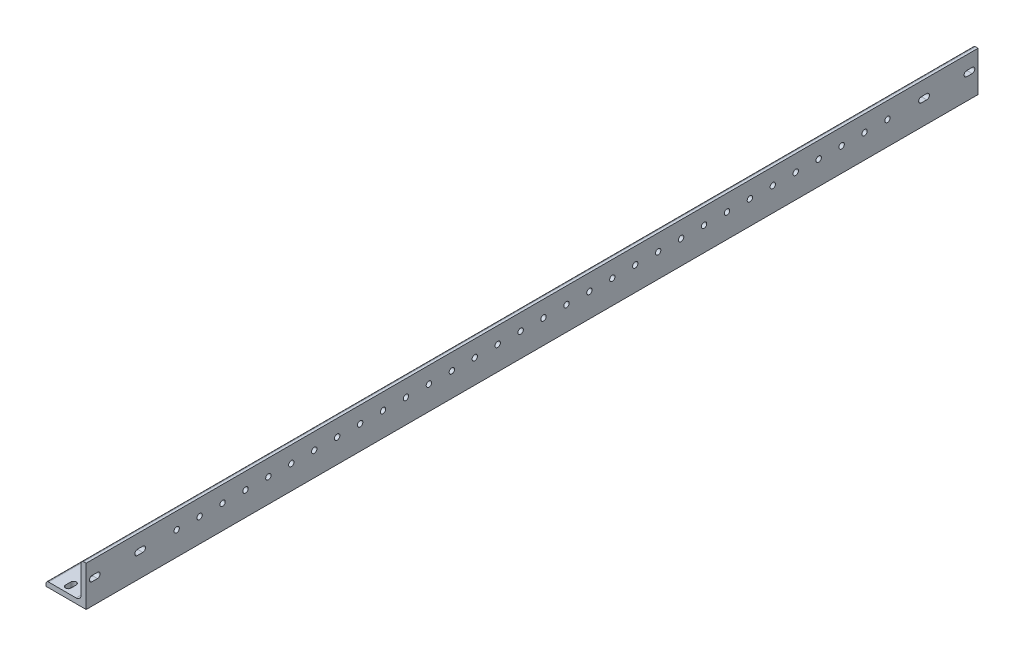
from build123d import *

# Parameters (mm, degrees)
BOSS_EXTRUDE1_DEPTH = 609.6
SKETCH3_W           = 655.2
SKETCH3_H           = 25.4
CUT_EXTRUDE2_DEPTH  = 30.48
SKETCH4_R           = 1.7
CUT_EXTRUDE4_DEPTH  = 611.137198198
SKETCH7_R           = 1.7
CUT_EXTRUDE6_DEPTH  = 611.137198198
CUT_EXTRUDE7_DEPTH  = 611.137198198
CUT_EXTRUDE8_DEPTH  = 611.137198198


with BuildPart() as part:
    # Sketch2 → Boss-Extrude1 (new, symmetric)
    with BuildSketch(Plane.XY):
        with BuildLine():
            Line((-12.7, -12.7), (12.7, -12.7))
            Line((12.7, -12.7), (12.7, 12.7))
            Line((12.7, 12.7), (11.1125, 12.7))
            ThreePointArc((11.1125, 12.7), (9.989967985, 12.235032015), (9.525, 11.1125))
            Line((9.525, 11.1125), (9.525, -6.35))
            ThreePointArc((9.525, -6.35), (8.59506403, -8.59506403), (6.35, -9.525))
            Line((6.35, -9.525), (-11.1125, -9.525))
            ThreePointArc((-11.1125, -9.525), (-12.235032015, -9.989967985), (-12.7, -11.1125))
            Line((-12.7, -11.1125), (-12.7, -12.7))
        make_face()
    extrude(amount=BOSS_EXTRUDE1_DEPTH, both=True)

    # Sketch3 → Cut-Extrude2 (cut)
    with BuildSketch(Plane(origin=(12.7, 0, 0), x_dir=(0, 0, -1), z_dir=(1, 0, 0))):
        with Locations((282, 0)):
            Rectangle(SKETCH3_W, SKETCH3_H)
    extrude(amount=-CUT_EXTRUDE2_DEPTH, mode=Mode.SUBTRACT)

    # Sketch4 → Cut-Extrude4 (cut, through all)
    with BuildSketch(Plane(origin=(0, -9.525, 0), x_dir=(1, 0, 0), z_dir=(0, 1, 0))):
        with Locations(Location((-2.38125, -552.35, 0), (0, 0, 180))):
            Circle(SKETCH4_R)
        with Locations(Location((-2.38125, -537.85, 0), (0, 0, 180))):
            Circle(SKETCH4_R)
        with Locations(Location((-2.38125, -523.35, 0), (0, 0, 180))):
            Circle(SKETCH4_R)
        with Locations(Location((-2.38125, -508.85, 0), (0, 0, 180))):
            Circle(SKETCH4_R)
        with Locations(Location((-2.38125, -494.35, 0), (0, 0, 180))):
            Circle(SKETCH4_R)
        with Locations(Location((-2.38125, -479.85, 0), (0, 0, 180))):
            Circle(SKETCH4_R)
        with Locations(Location((-2.38125, -465.35, 0), (0, 0, 180))):
            Circle(SKETCH4_R)
        with Locations(Location((-2.38125, -450.85, 0), (0, 0, 180))):
            Circle(SKETCH4_R)
        with Locations(Location((-2.38125, -436.35, 0), (0, 0, 180))):
            Circle(SKETCH4_R)
        with Locations(Location((-2.38125, -421.85, 0), (0, 0, 180))):
            Circle(SKETCH4_R)
        with Locations(Location((-2.38125, -407.35, 0), (0, 0, 180))):
            Circle(SKETCH4_R)
        with Locations(Location((-2.38125, -392.85, 0), (0, 0, 180))):
            Circle(SKETCH4_R)
        with Locations(Location((-2.38125, -378.35, 0), (0, 0, 180))):
            Circle(SKETCH4_R)
        with Locations(Location((-2.38125, -363.85, 0), (0, 0, 180))):
            Circle(SKETCH4_R)
        with Locations(Location((-2.38125, -349.35, 0), (0, 0, 180))):
            Circle(SKETCH4_R)
        with Locations(Location((-2.38125, -334.85, 0), (0, 0, 180))):
            Circle(SKETCH4_R)
        with Locations(Location((-2.38125, -320.35, 0), (0, 0, 180))):
            Circle(SKETCH4_R)
        with Locations(Location((-2.38125, -305.85, 0), (0, 0, 180))):
            Circle(SKETCH4_R)
        with Locations(Location((-2.38125, -291.35, 0), (0, 0, 180))):
            Circle(SKETCH4_R)
        with Locations(Location((-2.38125, -276.85, 0), (0, 0, 180))):
            Circle(SKETCH4_R)
        with Locations(Location((-2.38125, -262.35, 0), (0, 0, 180))):
            Circle(SKETCH4_R)
        with Locations(Location((-2.38125, -247.85, 0), (0, 0, 180))):
            Circle(SKETCH4_R)
        with Locations(Location((-2.38125, -233.35, 0), (0, 0, 180))):
            Circle(SKETCH4_R)
        with Locations(Location((-2.38125, -218.85, 0), (0, 0, 180))):
            Circle(SKETCH4_R)
        with Locations(Location((-2.38125, -204.35, 0), (0, 0, 180))):
            Circle(SKETCH4_R)
        with Locations(Location((-2.38125, -189.85, 0), (0, 0, 180))):
            Circle(SKETCH4_R)
        with Locations(Location((-2.38125, -175.35, 0), (0, 0, 180))):
            Circle(SKETCH4_R)
        with Locations(Location((-2.38125, -160.85, 0), (0, 0, 180))):
            Circle(SKETCH4_R)
        with Locations(Location((-2.38125, -146.35, 0), (0, 0, 180))):
            Circle(SKETCH4_R)
        with Locations(Location((-2.38125, -131.85, 0), (0, 0, 180))):
            Circle(SKETCH4_R)
        with Locations(Location((-2.38125, -117.35, 0), (0, 0, 180))):
            Circle(SKETCH4_R)
        with Locations(Location((-2.38125, -102.85, 0), (0, 0, 180))):
            Circle(SKETCH4_R)
    extrude(amount=-CUT_EXTRUDE4_DEPTH, mode=Mode.SUBTRACT)

    # Sketch7 → Cut-Extrude6 (cut, through all)
    with BuildSketch(Plane.ZY.offset(-9.525)):
        with Locations(Location((552.35, 2.38125, 0), (0, 0, 270))):
            Circle(SKETCH7_R)
        with Locations(Location((537.85, 2.38125, 0), (0, 0, 270))):
            Circle(SKETCH7_R)
        with Locations(Location((523.35, 2.38125, 0), (0, 0, 270))):
            Circle(SKETCH7_R)
        with Locations(Location((508.85, 2.38125, 0), (0, 0, 270))):
            Circle(SKETCH7_R)
        with Locations(Location((494.35, 2.38125, 0), (0, 0, 270))):
            Circle(SKETCH7_R)
        with Locations(Location((479.85, 2.38125, 0), (0, 0, 270))):
            Circle(SKETCH7_R)
        with Locations(Location((465.35, 2.38125, 0), (0, 0, 270))):
            Circle(SKETCH7_R)
        with Locations(Location((450.85, 2.38125, 0), (0, 0, 270))):
            Circle(SKETCH7_R)
        with Locations(Location((436.35, 2.38125, 0), (0, 0, 270))):
            Circle(SKETCH7_R)
        with Locations(Location((421.85, 2.38125, 0), (0, 0, 270))):
            Circle(SKETCH7_R)
        with Locations(Location((407.35, 2.38125, 0), (0, 0, 270))):
            Circle(SKETCH7_R)
        with Locations(Location((392.85, 2.38125, 0), (0, 0, 270))):
            Circle(SKETCH7_R)
        with Locations(Location((378.35, 2.38125, 0), (0, 0, 270))):
            Circle(SKETCH7_R)
        with Locations(Location((363.85, 2.38125, 0), (0, 0, 270))):
            Circle(SKETCH7_R)
        with Locations(Location((349.35, 2.38125, 0), (0, 0, 270))):
            Circle(SKETCH7_R)
        with Locations(Location((334.85, 2.38125, 0), (0, 0, 270))):
            Circle(SKETCH7_R)
        with Locations(Location((320.35, 2.38125, 0), (0, 0, 270))):
            Circle(SKETCH7_R)
        with Locations(Location((305.85, 2.38125, 0), (0, 0, 270))):
            Circle(SKETCH7_R)
        with Locations(Location((291.35, 2.38125, 0), (0, 0, 270))):
            Circle(SKETCH7_R)
        with Locations(Location((276.85, 2.38125, 0), (0, 0, 270))):
            Circle(SKETCH7_R)
        with Locations(Location((262.35, 2.38125, 0), (0, 0, 270))):
            Circle(SKETCH7_R)
        with Locations(Location((247.85, 2.38125, 0), (0, 0, 270))):
            Circle(SKETCH7_R)
        with Locations(Location((233.35, 2.38125, 0), (0, 0, 270))):
            Circle(SKETCH7_R)
        with Locations(Location((218.85, 2.38125, 0), (0, 0, 270))):
            Circle(SKETCH7_R)
        with Locations(Location((204.35, 2.38125, 0), (0, 0, 270))):
            Circle(SKETCH7_R)
        with Locations(Location((189.85, 2.38125, 0), (0, 0, 270))):
            Circle(SKETCH7_R)
        with Locations(Location((175.35, 2.38125, 0), (0, 0, 270))):
            Circle(SKETCH7_R)
        with Locations(Location((160.85, 2.38125, 0), (0, 0, 270))):
            Circle(SKETCH7_R)
        with Locations(Location((146.35, 2.38125, 0), (0, 0, 270))):
            Circle(SKETCH7_R)
        with Locations(Location((131.85, 2.38125, 0), (0, 0, 270))):
            Circle(SKETCH7_R)
        with Locations(Location((117.35, 2.38125, 0), (0, 0, 270))):
            Circle(SKETCH7_R)
        with Locations(Location((102.85, 2.38125, 0), (0, 0, 270))):
            Circle(SKETCH7_R)
    extrude(amount=-CUT_EXTRUDE6_DEPTH, mode=Mode.SUBTRACT)

    # Sketch8 → Cut-Extrude7 (cut, through all)
    with BuildSketch(Plane.ZY.offset(-9.525)):
        with BuildLine():
            Line((49.3305, 4.0825), (52.7305, 4.0825))
            ThreePointArc((52.7305, 4.0825), (54.4305, 2.3825), (52.7305, 0.6825))
            Line((52.7305, 0.6825), (49.3305, 0.6825))
            ThreePointArc((49.3305, 0.6825), (47.6305, 2.3825), (49.3305, 4.0825))
        make_face()
        with BuildLine():
            Line((78.0325, 4.0825), (81.4325, 4.0825))
            ThreePointArc((81.4325, 4.0825), (83.1325, 2.3825), (81.4325, 0.6825))
            Line((81.4325, 0.6825), (78.0325, 0.6825))
            ThreePointArc((78.0325, 0.6825), (76.3325, 2.3825), (78.0325, 4.0825))
        make_face()
        with BuildLine():
            Line((573.7675, 4.0825), (577.1675, 4.0825))
            ThreePointArc((577.1675, 4.0825), (578.8675, 2.3825), (577.1675, 0.6825))
            Line((577.1675, 0.6825), (573.7675, 0.6825))
            ThreePointArc((573.7675, 0.6825), (572.0675, 2.3825), (573.7675, 4.0825))
        make_face()
        with BuildLine():
            Line((602.4695, 4.0825), (605.8695, 4.0825))
            ThreePointArc((605.8695, 4.0825), (607.5695, 2.3825), (605.8695, 0.6825))
            Line((605.8695, 0.6825), (602.4695, 0.6825))
            ThreePointArc((602.4695, 0.6825), (600.7695, 2.3825), (602.4695, 4.0825))
        make_face()
    extrude(amount=-CUT_EXTRUDE7_DEPTH, mode=Mode.SUBTRACT)

    # Sketch9 → Cut-Extrude8 (cut, through all)
    with BuildSketch(Plane(origin=(0, -9.525, 0), x_dir=(1, 0, 0), z_dir=(0, 1, 0))):
        with BuildLine():
            Line((-4.0825, -605.8695), (-4.0825, -602.4695))
            ThreePointArc((-4.0825, -602.4695), (-2.3825, -600.7695), (-0.6825, -602.4695))
            Line((-0.6825, -602.4695), (-0.6825, -605.8695))
            ThreePointArc((-0.6825, -605.8695), (-2.3825, -607.5695), (-4.0825, -605.8695))
        make_face()
        with BuildLine():
            Line((-4.0825, -577.1675), (-4.0825, -573.7675))
            ThreePointArc((-4.0825, -573.7675), (-2.3825, -572.0675), (-0.6825, -573.7675))
            Line((-0.6825, -573.7675), (-0.6825, -577.1675))
            ThreePointArc((-0.6825, -577.1675), (-2.3825, -578.8675), (-4.0825, -577.1675))
        make_face()
        with BuildLine():
            Line((-4.0825, -81.4325), (-4.0825, -78.0325))
            ThreePointArc((-4.0825, -78.0325), (-2.3825, -76.3325), (-0.6825, -78.0325))
            Line((-0.6825, -78.0325), (-0.6825, -81.4325))
            ThreePointArc((-0.6825, -81.4325), (-2.3825, -83.1325), (-4.0825, -81.4325))
        make_face()
        with BuildLine():
            Line((-4.0825, -52.7305), (-4.0825, -49.3305))
            ThreePointArc((-4.0825, -49.3305), (-2.3825, -47.6305), (-0.6825, -49.3305))
            Line((-0.6825, -49.3305), (-0.6825, -52.7305))
            ThreePointArc((-0.6825, -52.7305), (-2.3825, -54.4305), (-4.0825, -52.7305))
        make_face()
    extrude(amount=-CUT_EXTRUDE8_DEPTH, mode=Mode.SUBTRACT)


solid = part.part
